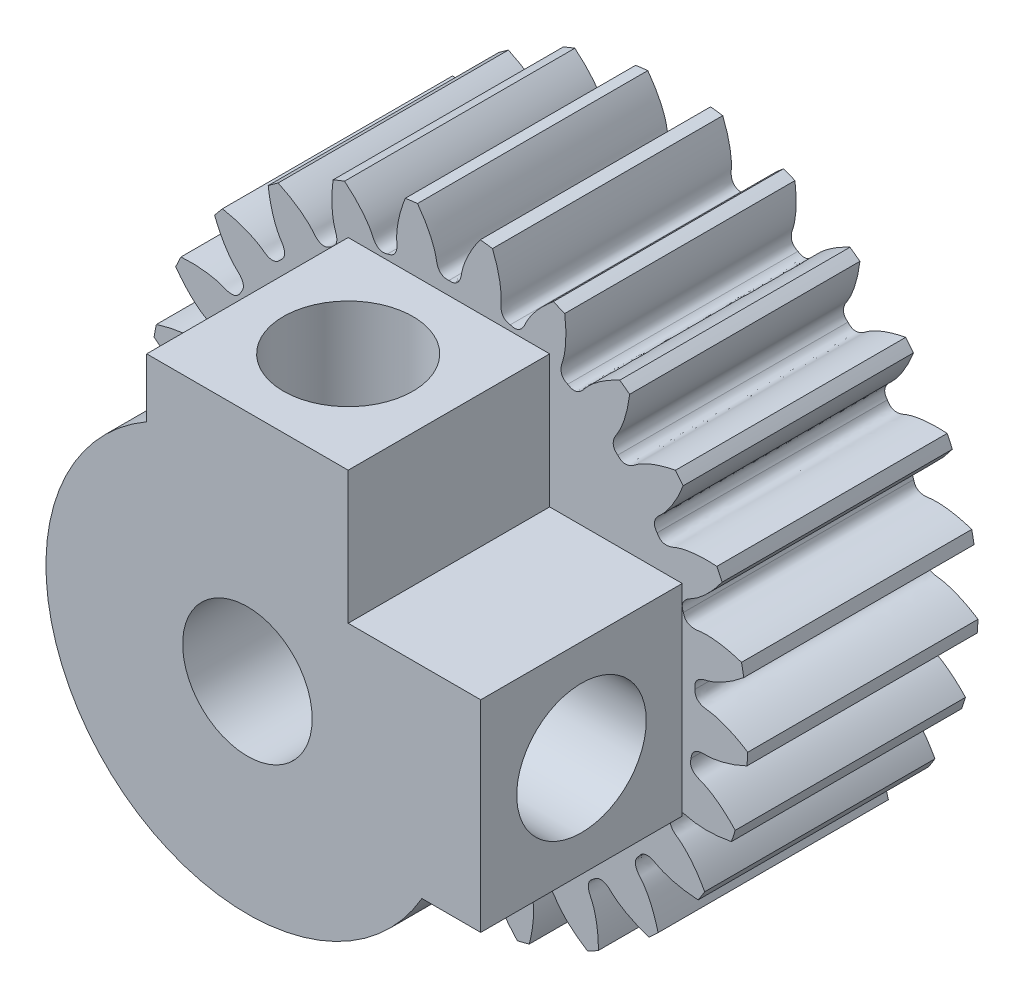
from build123d import *

# Parameters (mm, degrees)
GEAR_BASESKETCH_R                          = 10.39090909
F_33_0_DIAMETRAL_PITCH_20_78MM_P_D_DEPTH   = 4
TOOTH_CUT_FINE_PITCH_INVOLUTE_20_DEG_DEPTH = 16.229641606
TOOTH_PATTERN_25_25_COUNT                  = 25
SKETCH4_R                                  = 2.25
CUT_EXTRUDE2_DEPTH                         = 17.725702057
BOSS_EXTRUDE2_START                        = 7
SKETCH6_R                                  = 2.25
BOSS_EXTRUDE2_DEPTH                        = 7
SKETCH10_R                                 = 2.25
CUT_EXTRUDE3_DEPTH                         = 8
SKETCH11_R                                 = 2.25
CUT_EXTRUDE4_DEPTH                         = 8


with BuildPart() as part:
    # Gear-BaseSketch → 33.0 Diametral Pitch_ 20.78mm P.D (new, symmetric)
    with BuildSketch(Plane.XY):
        Circle(GEAR_BASESKETCH_R)
    extrude(amount=F_33_0_DIAMETRAL_PITCH_20_78MM_P_D_DEPTH, both=True)

    # Tooth-Sketch_ Backlash_ 0.0000mm → Tooth-Cut_ Fine Pitch Involute 20 deg (cut, symmetric)
    with BuildSketch(Plane.XY):
        with BuildLine():
            ThreePointArc((-1.090535488, 10.334041492), (0, 10.39090909), (1.090535488, 10.334041492))
            add(Edge.make_bspline(
                [(1.090535488, 10.334041492), (1.013795153, 10.229916505), (0.908217715, 10.075254093), (0.785065967, 9.868932322), (0.708772029, 9.728957559), (0.64415765, 9.598530961), (0.59034924, 9.478333291), (0.546438635, 9.368991153), (0.511484512, 9.271075533), (0.484521566, 9.185099676), (0.464544711, 9.111519651), (0.450566995, 9.050727608), (0.4416355, 9.003920489), (0.436546291, 8.969814506), (0.431988787, 8.944415524), (0.424644046, 8.908301024), (0.41223875, 8.859606811), (0.391188365, 8.799539512), (0.363821811, 8.742029463), (0.327186239, 8.68603597), (0.276085984, 8.632114942), (0.172421379, 8.564189407), (0.068061722, 8.559405999), (0, 8.564703587)],
                knots=[0, 0, 0, 0, 0.176710806, 0.255599559, 0.328177212, 0.394443766, 0.45439922, 0.508043574, 0.555376829, 0.596398984, 0.631110041, 0.659509998, 0.681598858, 0.696188565, 0.706615519, 0.716847673, 0.74653489, 0.775184615, 0.803670388, 0.833349652, 0.866218448, 0.904587235, 1, 1, 1, 1], degree=3))
            add(Edge.make_bspline(
                [(-1.090535488, 10.334041492), (-1.013795153, 10.229916505), (-0.908217715, 10.075254093), (-0.785065967, 9.868932322), (-0.708772029, 9.728957559), (-0.64415765, 9.598530961), (-0.59034924, 9.478333291), (-0.546438635, 9.368991153), (-0.511484512, 9.271075533), (-0.484521566, 9.185099676), (-0.464544711, 9.111519651), (-0.450566995, 9.050727608), (-0.4416355, 9.003920489), (-0.436546291, 8.969814506), (-0.431988787, 8.944415524), (-0.424644046, 8.908301024), (-0.41223875, 8.859606811), (-0.391188365, 8.799539512), (-0.363821811, 8.742029463), (-0.327186239, 8.68603597), (-0.276085984, 8.632114942), (-0.172421379, 8.564189407), (-0.068061722, 8.559405999), (0, 8.564703587)],
                knots=[0, 0, 0, 0, 0.176710806, 0.255599559, 0.328177212, 0.394443766, 0.45439922, 0.508043574, 0.555376829, 0.596398984, 0.631110041, 0.659509998, 0.681598858, 0.696188565, 0.706615519, 0.716847673, 0.74653489, 0.775184615, 0.803670388, 0.833349652, 0.866218448, 0.904587235, 1, 1, 1, 1], degree=3))
        make_face()
    tooth_cut_fine_pitch_involute_20_deg = extrude(amount=TOOTH_CUT_FINE_PITCH_INVOLUTE_20_DEG_DEPTH, both=True, mode=Mode.SUBTRACT)

    # Tooth Pattern_ 25 _ 25: Tooth-Cut_ Fine Pitch Involute 20 deg ×25 about axis
    tooth_pattern_25_25_axis = Axis((0, 0, -15.603217156), (0, 0, 1))
    for i in range(1, TOOTH_PATTERN_25_25_COUNT):
        add(tooth_cut_fine_pitch_involute_20_deg.rotate(tooth_pattern_25_25_axis, i * 360 / TOOTH_PATTERN_25_25_COUNT), mode=Mode.SUBTRACT)

    # Sketch4 → Cut-Extrude2 (cut, through all)
    with BuildSketch(Plane.XY.offset(4)):
        Circle(SKETCH4_R)
    extrude(amount=-CUT_EXTRUDE2_DEPTH, mode=Mode.SUBTRACT)

    # Sketch6 → Boss-Extrude2 (add)
    with BuildSketch(Plane.XY.offset(4).offset(BOSS_EXTRUDE2_START)):
        with BuildLine():
            Line((8.105666153, 3.5), (8.105666153, -3.5))
            Line((8.105666153, -3.5), (6.062177826, -3.5))
            ThreePointArc((6.062177826, -3.5), (-4.949747468, -4.949747468), (-3.5, 6.062177826))
            Line((-3.5, 6.062177826), (-3.5, 8.105666153))
            Line((-3.5, 8.105666153), (3.5, 8.105666153))
            Line((3.5, 8.105666153), (3.5, 3.5))
            Line((3.5, 3.5), (8.105666153, 3.5))
        make_face()
        Circle(SKETCH6_R, mode=Mode.SUBTRACT)
    extrude(amount=-BOSS_EXTRUDE2_DEPTH)

    # Sketch10 → Cut-Extrude3 (cut)
    with BuildSketch(Plane(origin=(0, 8.105666153, 0), x_dir=(1, 0, 0), z_dir=(0, 1, 0))):
        with Locations((0, -7.5)):
            Circle(SKETCH10_R)
    extrude(amount=-CUT_EXTRUDE3_DEPTH, mode=Mode.SUBTRACT)

    # Sketch11 → Cut-Extrude4 (cut)
    with BuildSketch(Plane(origin=(8.105666153, 0, 0), x_dir=(0, 0, -1), z_dir=(1, 0, 0))):
        with Locations((-7.5, 0)):
            Circle(SKETCH11_R)
    extrude(amount=-CUT_EXTRUDE4_DEPTH, mode=Mode.SUBTRACT)


solid = part.part
